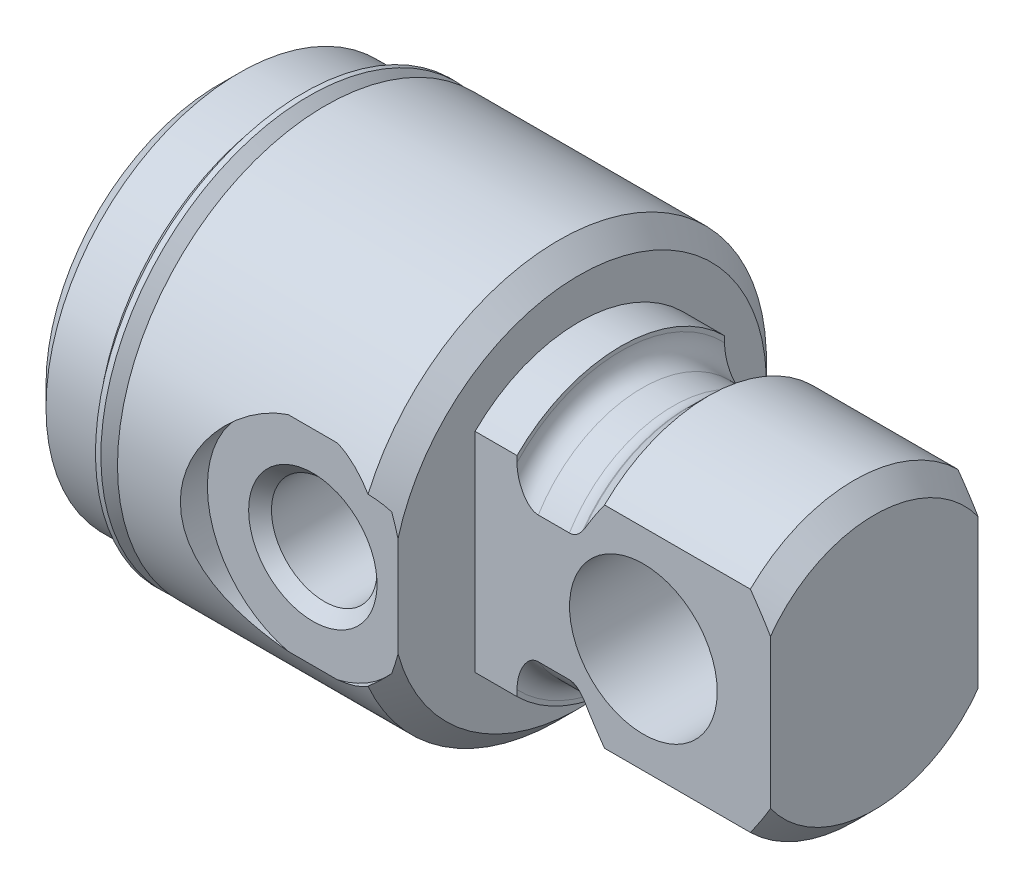
from build123d import *

# Parameters (mm, degrees)
SKETCH3_W               = 31.242
SKETCH3_H               = 62.484
SKETCH3_W_2             = 7.7978
SKETCH3_H_2             = 31.242
CUT_EXTRUDE1_DEPTH      = 11.0998
HOLE1_D                 = 3.9116
HOLE1_DEPTH             = 12.2936
HOLE1_TIP               = 1.129181656
CUT_EXTRUDE2_DEPTH      = 5.84835
CUT_EXTRUDE2_DEPTH_BACK = 5.84835
SKETCH8_R               = 2.77495


with BuildPart() as part:
    # Sketch1 → Revolve1 (revolve)
    with BuildSketch(Plane.XY):
        Polygon((0, 0), (0, 6.50875), (0.762, 7.27075), (2.7178, 7.27075), (3.3528, 6.63575), (3.9878, 6.63575), (3.9878, 7.8105), (12.7508, 7.8105), (13.5128, 7.0485), (13.5128, 0), align=None)
    revolve(axis=Axis((13.5128, 0, 0), (-1, 0, 0)))

    # Sketch2 → Revolve2 (revolve)
    with BuildSketch(Plane.XY):
        with BuildLine():
            Line((13.5128, 0), (13.5128, 5.53085))
            Line((13.5128, 5.53085), (15.0876, 5.53085))
            Line((15.0876, 5.53085), (15.0876, 5.3721))
            ThreePointArc((15.0876, 5.3721), (15.321943864, 4.806343864), (15.8877, 4.572))
            Line((15.8877, 4.572), (17.0561, 4.572))
            ThreePointArc((17.0561, 4.572), (17.3228, 4.617758486), (17.558994343, 4.7498))
            Line((17.558994343, 4.7498), (17.621856136, 4.8006))
            Line((17.621856136, 4.8006), (18.377506136, 5.55625))
            Line((18.377506136, 5.55625), (23.85695, 5.55625))
            Line((23.85695, 5.55625), (24.6126, 4.8006))
            Line((24.6126, 4.8006), (24.6126, 0))
            Line((24.6126, 0), (13.5128, 0))
        make_face()
    revolve(axis=Axis((24.6126, 0, 0), (-1, 0, 0)))

    # Sketch3 → Cut-Extrude1 (cut)
    with BuildSketch(Plane(origin=(24.6126, 0, 0), x_dir=(0, 0, -1), z_dir=(1, 0, 0))):
        Rectangle(SKETCH3_W, SKETCH3_H)
        Rectangle(SKETCH3_W_2, SKETCH3_H_2, mode=Mode.SUBTRACT)
    extrude(amount=-CUT_EXTRUDE1_DEPTH, mode=Mode.SUBTRACT)

    # Hole1
    with Locations(Plane.ZY):
        with Locations((0, 0)):
            Hole(HOLE1_D / 2, depth=HOLE1_DEPTH)
            with Locations((0, 0, -(HOLE1_DEPTH + HOLE1_TIP / 2))):  # 120° drill point
                Cone(0, HOLE1_D / 2, HOLE1_TIP, mode=Mode.SUBTRACT)

    # Sketch6 → Cut-Revolve1 (revolve, cut)
    with BuildSketch(Plane(origin=(0, 0, 0), x_dir=(1, 0, 0), z_dir=(0, 1, 0))):
        Polygon((10.3124, 0), (12.29614, 0), (12.29614, -6.36524), (12.7254, -6.7945), (14.2748, -6.7945), (14.2748, -7.8105), (10.3124, -7.8105), align=None)
    revolve(axis=Axis((10.3124, 0, 7.8105), (0, 0, -1)), mode=Mode.SUBTRACT)

    # Sketch7 → Revolve3 (revolve)
    with BuildSketch(Plane.XY):
        with BuildLine():
            Line((3.160243808, 7.726331804), (3.870760245, 7.015815367))
            ThreePointArc((3.870760245, 7.015815367), (3.907957684, 6.926012806), (3.870760245, 6.836210245))
            Line((3.870760245, 6.836210245), (3.6703, 6.63575))
            Line((3.6703, 6.63575), (3.3528, 6.63575))
            Line((3.3528, 6.63575), (3.3528, 6.38175))
            Line((3.3528, 6.38175), (3.9878, 6.38175))
            Line((3.9878, 6.38175), (3.9878, 7.186143808))
            Line((3.9878, 7.186143808), (3.363443808, 7.8105))
            Line((3.363443808, 7.8105), (3.160243808, 7.8105))
            Line((3.160243808, 7.8105), (3.160243808, 7.726331804))
        make_face()
    revolve(axis=Axis((3.9878, 0, 0), (-1, 0, 0)))

    # Sketch8 → Cut-Extrude2 (cut, two sides: drawn at the far end of the back side and taken through both)
    with BuildSketch(Plane.XY.offset(-CUT_EXTRUDE2_DEPTH_BACK)):
        with Locations((19.8374, 0)):
            Circle(SKETCH8_R)
    extrude(amount=CUT_EXTRUDE2_DEPTH + CUT_EXTRUDE2_DEPTH_BACK, mode=Mode.SUBTRACT)


solid = part.part
